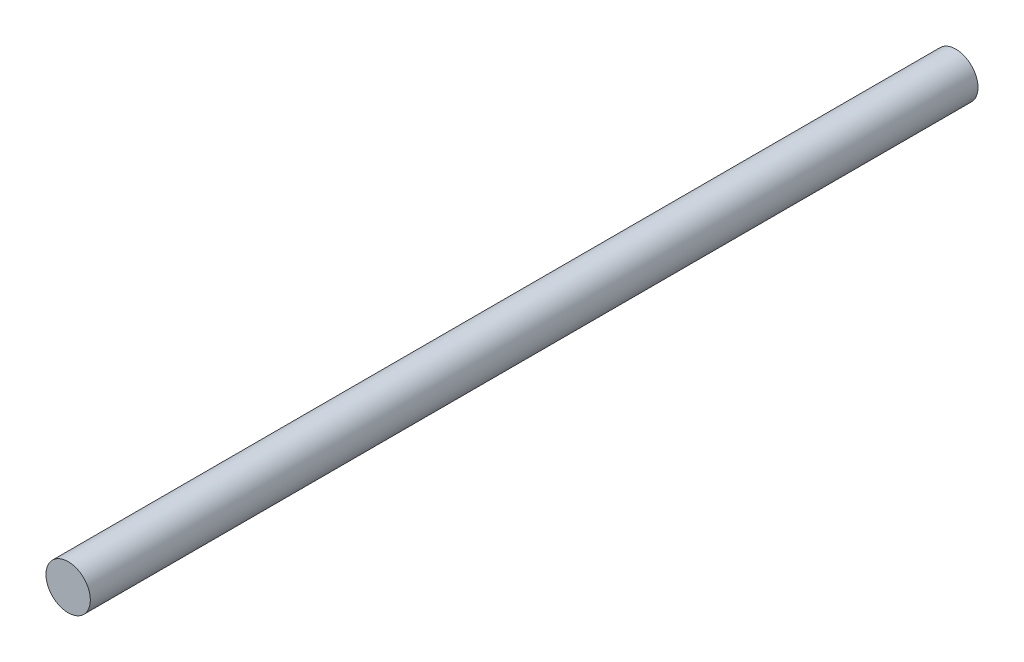
from build123d import *

# Parameters (mm, degrees)
SKETCH1_R           = 6.35
BOSS_EXTRUDE1_DEPTH = 254


with BuildPart() as part:
    # Sketch1 → Boss-Extrude1 (new body)
    with BuildSketch(Plane.XY):
        Circle(SKETCH1_R)
    extrude(amount=BOSS_EXTRUDE1_DEPTH)


solid = part.part
